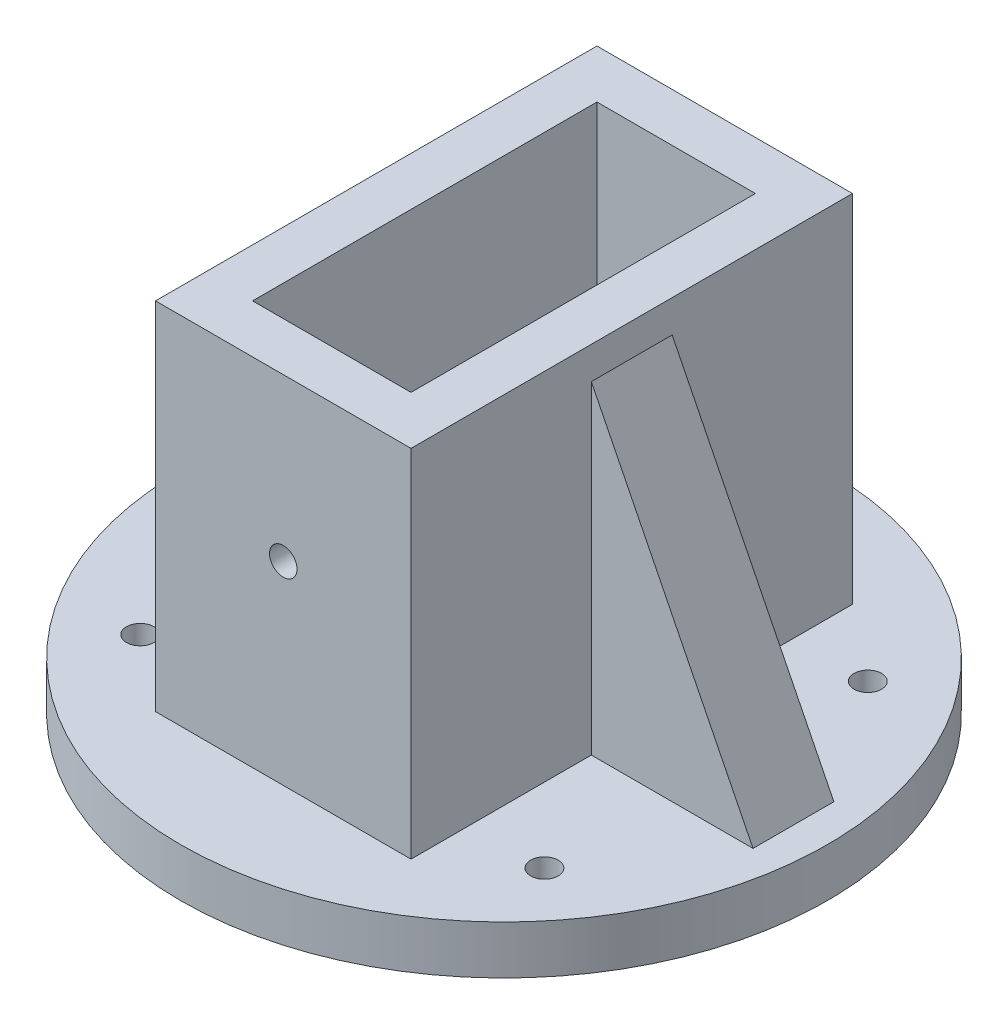
from build123d import *

# Parameters (mm, degrees)
CROQUIS1_W              = 31.6
CROQUIS1_H              = 54.6
CROQUIS1_W_2            = 19.6
CROQUIS1_H_2            = 42.6
SALIENTE_EXTRUIR1_DEPTH = 50
CROQUIS2_R              = 40
SALIENTE_EXTRUIR2_DEPTH = 6
NERVIO4_REACH           = 77.498
CROQUIS3_WALL_W         = 197.718048256
CROQUIS3_WALL_H         = 10
CROQUIS4_R              = 1.7
CORTAR_EXTRUIR1_DEPTH   = 10
CROQUIS5_R              = 1.7
CORTAR_EXTRUIR2_DEPTH   = 60


with BuildPart() as part:
    # Croquis1 → Saliente-Extruir1 (new body)
    with BuildSketch(Plane(origin=(0, 0, 0), x_dir=(1, 0, 0), z_dir=(0, 1, 0))):
        Rectangle(CROQUIS1_W, CROQUIS1_H)
        Rectangle(CROQUIS1_W_2, CROQUIS1_H_2, mode=Mode.SUBTRACT)
    extrude(amount=SALIENTE_EXTRUIR1_DEPTH)

    # Croquis2 → Saliente-Extruir2 (add)
    with BuildSketch(Plane(origin=(0, 0, 0), x_dir=(-1, 0, 0), z_dir=(0, -1, 0))):
        with Locations(Location((0, 0, 0), (0, 0, 90))):
            Circle(CROQUIS2_R)
    extrude(amount=-SALIENTE_EXTRUIR2_DEPTH)

    # Croquis3 wall → Nervio4 (add, up to next)
    with BuildSketch(Plane(origin=(-25.8, 26, 0), x_dir=(-0.4472135955, -0.894427191, 0), z_dir=(0.894427191, -0.4472135955, 0)), mode=Mode.PRIVATE) as nervio4_sk1:
        Rectangle(CROQUIS3_WALL_W, CROQUIS3_WALL_H)
    nervio4_tool1 = extrude(nervio4_sk1.sketch, amount=NERVIO4_REACH, mode=Mode.PRIVATE) - part.part
    nervio4 = nervio4_tool1.solids().sort_by_distance((-25.8, 26, 0))[0]
    add(nervio4)

    # Simetría1: Nervio4 across plane
    add(nervio4.mirror(Plane(origin=(0, 0, 0), x_dir=(0, 0, 1), z_dir=(1, 0, 0))))

    # Croquis4 → Cortar-Extruir1 (cut)
    with BuildSketch(Plane(origin=(0, 6, 0), x_dir=(1, 0, 0), z_dir=(0, 1, 0))):
        with Locations(Location((-25, 20, 0), (0, 0, 270))):
            Circle(CROQUIS4_R)
        with Locations(Location((-25, -20, 0), (0, 0, 270))):
            Circle(CROQUIS4_R)
        with Locations(Location((25, -20, 0), (0, 0, 270))):
            Circle(CROQUIS4_R)
        with Locations(Location((25, 20, 0), (0, 0, 270))):
            Circle(CROQUIS4_R)
    extrude(amount=-CORTAR_EXTRUIR1_DEPTH, mode=Mode.SUBTRACT)

    # Croquis5 → Cortar-Extruir2 (cut)
    with BuildSketch(Plane.XY.offset(27.3)):
        with Locations((0, 30)):
            Circle(CROQUIS5_R)
    extrude(amount=-CORTAR_EXTRUIR2_DEPTH, mode=Mode.SUBTRACT)


solid = part.part
